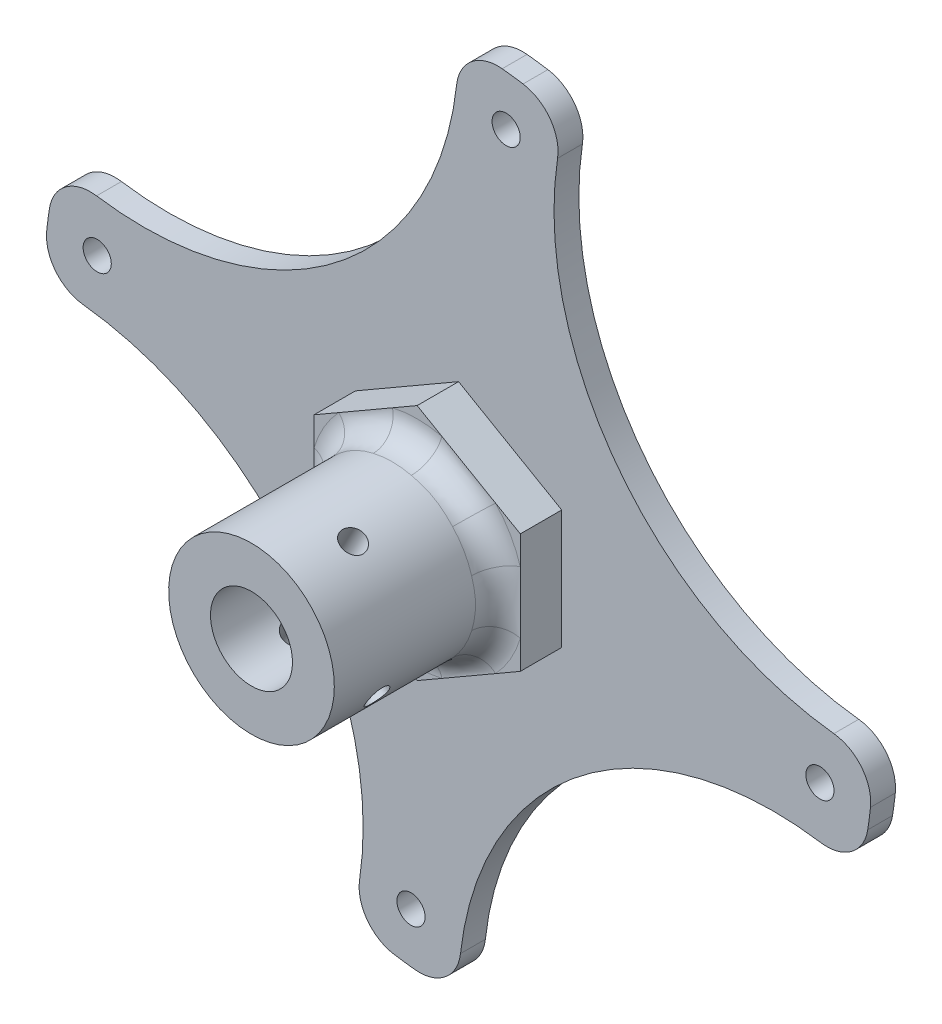
from build123d import *

# Parameters (mm, degrees)
SKETCH1_R                           = 50
BOSS_EXTRUDE1_DEPTH                 = 3
BOSS_EXTRUDE2_DEPTH                 = 5
SKETCH3_R                           = 10
BOSS_EXTRUDE3_DEPTH                 = 20
FILLET1_R                           = 3
SKETCH4_R                           = 4.95
CUT_EXTRUDE1_DEPTH                  = 29
F_1_0MM_DOWEL_HOLE1_D               = 2.8
F_1_0MM_DOWEL_HOLE1_DEPTH           = 33.158795133
F_1_0MM_DOWEL_HOLE1_TIP             = 0.841204867
F_1_0MM_DOWEL_HOLE1_ON_FACE_2_D     = 2.8
F_1_0MM_DOWEL_HOLE1_ON_FACE_2_DEPTH = 33.158795133
F_1_0MM_DOWEL_HOLE1_ON_FACE_2_TIP   = 0.841204867
CUT_EXTRUDE2_DEPTH                  = 25
FILLET2_R                           = 5
F_1_0MM_DOWEL_HOLE2_D               = 3.4
F_1_0MM_DOWEL_HOLE2_DEPTH           = 32.978536948
F_1_0MM_DOWEL_HOLE2_TIP             = 1.021463052


with BuildPart() as part:
    # Sketch1 → Boss-Extrude1 (new body)
    with BuildSketch(Plane.XY):
        Circle(SKETCH1_R)
    extrude(amount=BOSS_EXTRUDE1_DEPTH)

    # Sketch2 → Boss-Extrude2 (add)
    with BuildSketch(Plane.XY.offset(3)):
        Polygon((12.45, -7.188010851), (12.45, 7.188010851), (0, 14.376021703), (-12.45, 7.188010851), (-12.45, -7.188010851), (0, -14.376021703), align=None)
    extrude(amount=BOSS_EXTRUDE2_DEPTH)

    # Sketch3 → Boss-Extrude3 (add)
    with BuildSketch(Plane.XY.offset(8)):
        Circle(SKETCH3_R)
    extrude(amount=BOSS_EXTRUDE3_DEPTH)

    # Fillet1
    fillet1_edges = [part.edges().sort_by_distance(p)[0] for p in [
        (-10, 0, 8),
    ]]
    fillet(fillet1_edges, radius=FILLET1_R)

    # Sketch4 → Cut-Extrude1 (cut, through all)
    with BuildSketch(Plane.XY.offset(28)):
        Circle(SKETCH4_R)
    extrude(amount=-CUT_EXTRUDE1_DEPTH, mode=Mode.SUBTRACT)

    # Ø1.0mm Dowel Hole1
    with Locations(Plane(origin=(-8.66652473, 4.98912308, 21.499193451), x_dir=(-0.498912308, -0.866652473, 0), z_dir=(-0.866652473, 0.498912308, 0))):
        with Locations((-1e-09, 0)):
            Hole(F_1_0MM_DOWEL_HOLE1_D / 2, depth=F_1_0MM_DOWEL_HOLE1_DEPTH)
            with Locations((0, 0, -(F_1_0MM_DOWEL_HOLE1_DEPTH + F_1_0MM_DOWEL_HOLE1_TIP / 2))):  # 118° drill point
                Cone(0, F_1_0MM_DOWEL_HOLE1_D / 2, F_1_0MM_DOWEL_HOLE1_TIP, mode=Mode.SUBTRACT)

    # Ø1.0mm Dowel Hole1 on face 2
    with Locations(Plane(origin=(4.73855937, 8.806023796, 20.457550219), x_dir=(0.880602268, -0.473856144, 0), z_dir=(0.473856144, 0.880602268, 0))):
        with Locations((0, 0)):
            Hole(F_1_0MM_DOWEL_HOLE1_ON_FACE_2_D / 2, depth=F_1_0MM_DOWEL_HOLE1_ON_FACE_2_DEPTH)
            with Locations((0, 0, -(F_1_0MM_DOWEL_HOLE1_ON_FACE_2_DEPTH + F_1_0MM_DOWEL_HOLE1_ON_FACE_2_TIP / 2))):  # 118° drill point
                Cone(0, F_1_0MM_DOWEL_HOLE1_ON_FACE_2_D / 2, F_1_0MM_DOWEL_HOLE1_ON_FACE_2_TIP, mode=Mode.SUBTRACT)

    # Sketch6 → Cut-Extrude2 (cut)
    with BuildSketch(Plane.XY.offset(3)):
        with BuildLine():
            ThreePointArc((0, 50), (-30.43807145, 39.667667015), (-48.296291314, 12.940952255))
            Line((-48.296291314, 12.940952255), (-47.366278478, 12.691756067))
            ThreePointArc((-47.366278478, 12.691756067), (-14.483944315, 19.666646244), (0, 50))
        make_face()
        with BuildLine():
            ThreePointArc((50, 0), (39.667667015, 30.43807145), (12.940952255, 48.296291314))
            ThreePointArc((12.940952255, 48.296291314), (19.371163, 14.864016159), (50, 0))
        make_face()
        with BuildLine():
            ThreePointArc((48.296291314, -12.940952255), (14.864016159, -19.371163), (0, -50))
            ThreePointArc((0, -50), (30.43807145, -39.667667015), (48.296291314, -12.940952255))
        make_face()
        with BuildLine():
            Line((-49.037179863, 0), (-50, 0))
            ThreePointArc((-50, 0), (-39.667667015, -30.43807145), (-12.940952255, -48.296291314))
            ThreePointArc((-12.940952255, -48.296291314), (-19.080518481, -15.247800886), (-49.037179863, 0))
        make_face()
    extrude(amount=-CUT_EXTRUDE2_DEPTH, mode=Mode.SUBTRACT)

    # Fillet2
    fillet2_edges = [part.edges().sort_by_distance(p)[0] for p in [
        (-48.296291314, 12.940952255, 1.5),
        (-50, 0, 1.5),
        (-12.940952255, -48.296291314, 1.5),
        (48.296291314, -12.940952255, 1.5),
        (0, -50, 1.5),
        (12.940952255, 48.296291314, 1.5),
        (50, 0, 1.5),
        (0, 50, 1.5),
    ]]
    fillet(fillet2_edges, radius=FILLET2_R)

    # Ø1.0mm Dowel Hole2
    with Locations(Plane(origin=(5.743152458, 43.6235739, 0), x_dir=(-1, 0, 0), z_dir=(0, 0, -1))):
        with Locations((0, 0), (49.366726358, -37.880421442), (11.486304916, -87.2471478), (-37.880421442, -49.366726358)):
            Hole(F_1_0MM_DOWEL_HOLE2_D / 2, depth=F_1_0MM_DOWEL_HOLE2_DEPTH)
            with Locations((0, 0, -(F_1_0MM_DOWEL_HOLE2_DEPTH + F_1_0MM_DOWEL_HOLE2_TIP / 2))):  # 118° drill point
                Cone(0, F_1_0MM_DOWEL_HOLE2_D / 2, F_1_0MM_DOWEL_HOLE2_TIP, mode=Mode.SUBTRACT)


solid = part.part
